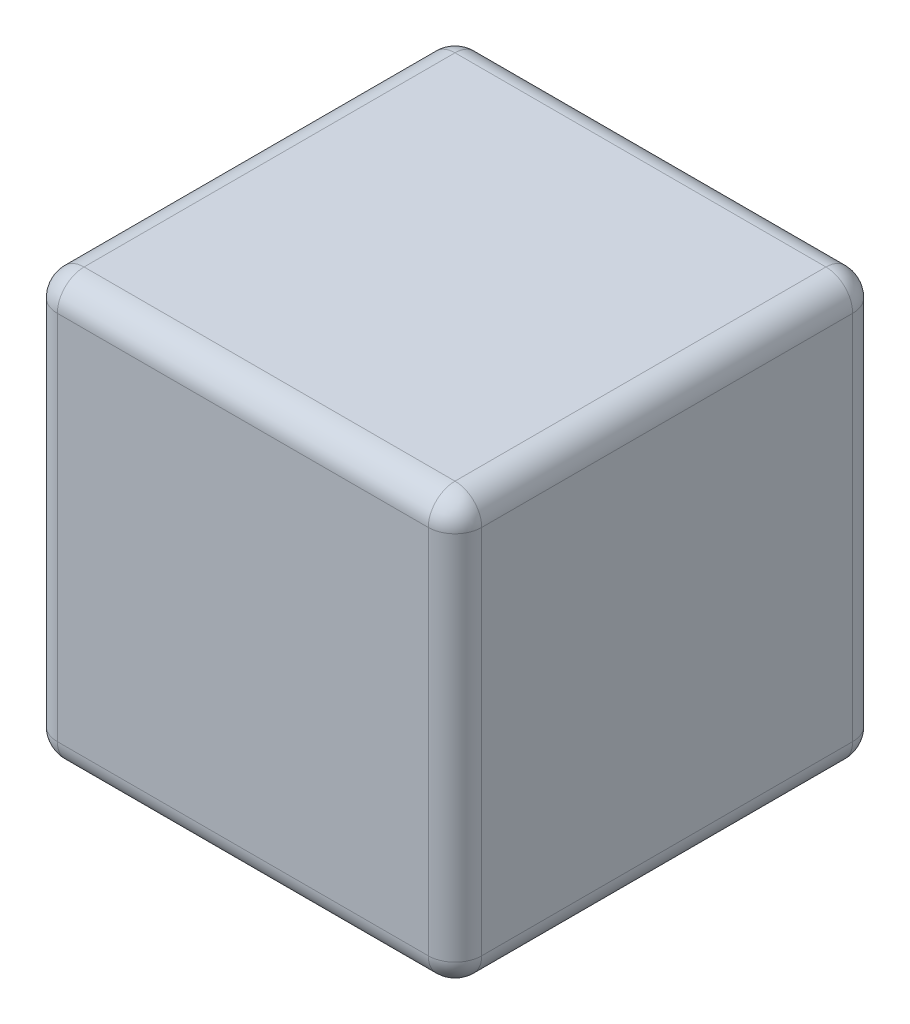
from build123d import *

# Parameters (mm, degrees)
SKETCH1_W           = 1.5875
SKETCH1_H           = 1.5875
BOSS_EXTRUDE1_DEPTH = 1.5875
FILLET1_R           = 0.1


with BuildPart() as part:
    # Sketch1 → Boss-Extrude1 (new body)
    with BuildSketch(Plane.XY):
        Rectangle(SKETCH1_W, SKETCH1_H)
    extrude(amount=BOSS_EXTRUDE1_DEPTH)

    # Fillet1
    fillet1_edges = [part.edges().sort_by_distance(p)[0] for p in [
        (-0.79375, 0, 1.5875),
        (0, -0.79375, 1.5875),
        (0.79375, 0, 1.5875),
        (0, -0.79375, 0),
        (-0.79375, 0, 0),
        (0, 0.79375, 0),
        (0.79375, 0, 0),
        (0.79375, -0.79375, 0.79375),
        (-0.79375, -0.79375, 0.79375),
        (-0.79375, 0.79375, 0.79375),
        (0.79375, 0.79375, 0.79375),
        (0, 0.79375, 1.5875),
    ]]
    fillet(fillet1_edges, radius=FILLET1_R)


solid = part.part
